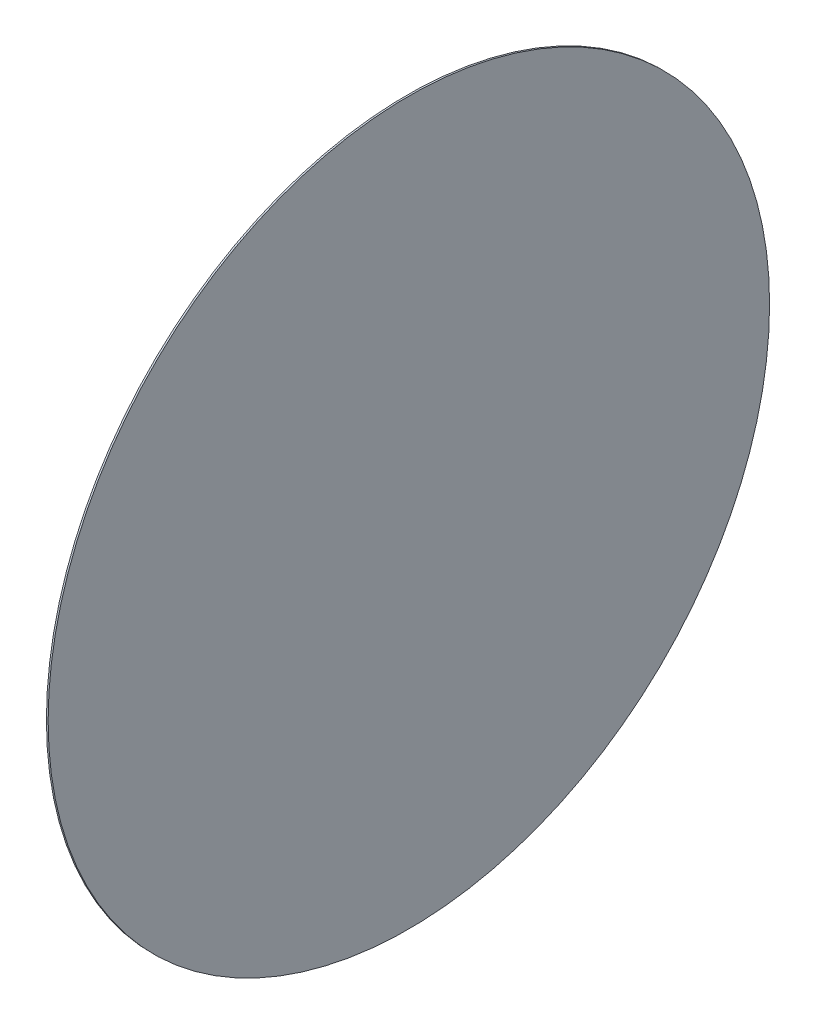
from build123d import *

# Parameters (mm, degrees)
SKETCH_1_W = 0.043
SKETCH_1_H = 9


with BuildPart() as part:
    # 草图1 → 旋转2 (revolve)
    with BuildSketch(Plane.XY, mode=Mode.PRIVATE) as revolve_2_sk:
        with Locations((0.0215, 4.5)):
            Rectangle(SKETCH_1_W, SKETCH_1_H)
    revolve(revolve_2_sk.sketch.rotate(Axis((0, 0, 0), (1, 0, 0)), 90), axis=Axis((0, 0, 0), (1, 0, 0)))  # turned: the seam where the file's is


solid = part.part
